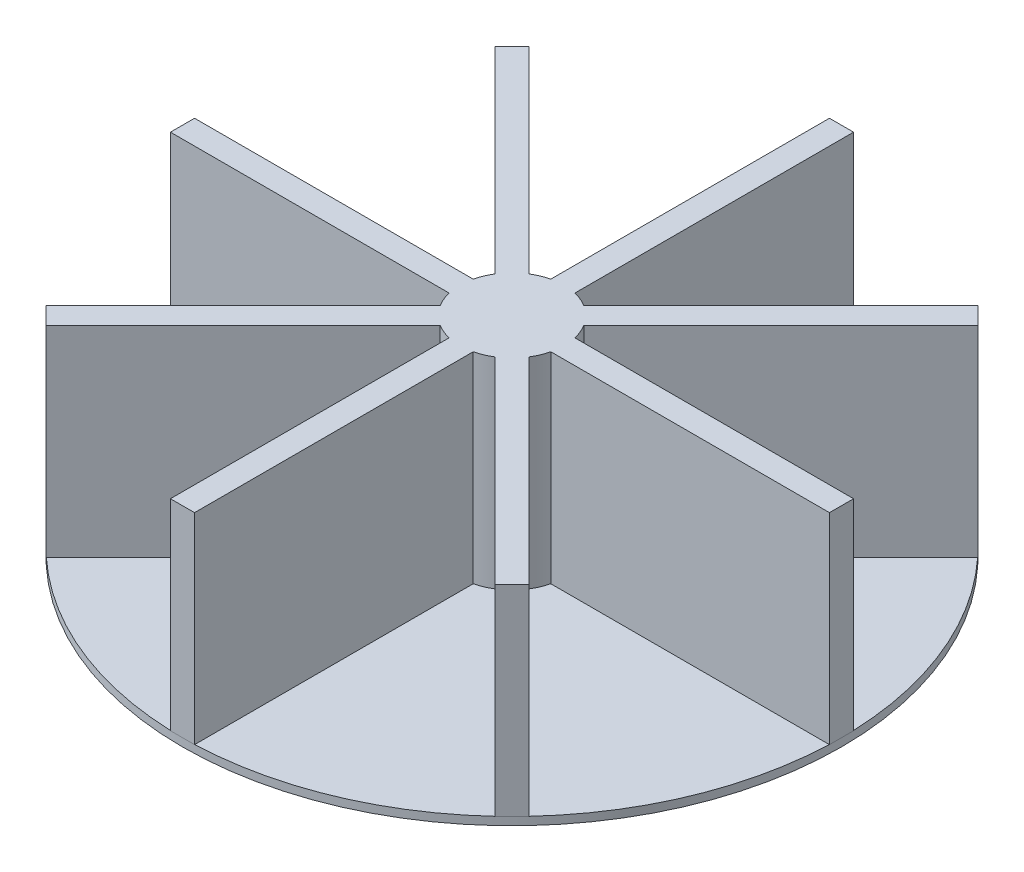
from build123d import *

# Parameters (mm, degrees)
SKETCH1_R            = 41
BOSS_EXTRUDE1_DEPTH  = 1
SKETCH6_W            = 3
SKETCH6_H            = 41
BOSS_EXTRUDE7_DEPTH  = 25
SKETCH7_R            = 6
BOSS_EXTRUDE8_DEPTH  = 24
SKETCH9_R            = 6
CUT_EXTRUDE3_DEPTH   = 5
CIRPATTERN1_COUNT    = 8
SKETCH11_R           = 6
CUT_EXTRUDE5_DEPTH   = 6
BOSS_EXTRUDE9_DEPTH  = 2
CIRPATTERN2_COUNT    = 8
FILLET1_R            = 1
SKETCH13_R           = 6.5
BOSS_EXTRUDE17_DEPTH = 6
SKETCH16_R           = 6.5
SKETCH16_R_2         = 6
BOSS_EXTRUDE18_DEPTH = 25
SKETCH15_R           = 6
BOSS_EXTRUDE19_DEPTH = 3
SKETCH17_R           = 3.075
CUT_EXTRUDE10_DEPTH  = 5


with BuildPart() as part:
    # Sketch1 → Boss-Extrude1 (new body)
    with BuildSketch(Plane(origin=(0, 0, 0), x_dir=(1, 0, 0), z_dir=(0, 1, 0))):
        Circle(SKETCH1_R)
    extrude(amount=BOSS_EXTRUDE1_DEPTH)

    # Sketch6 → Boss-Extrude7 (add)
    with BuildSketch(Plane(origin=(0, 1, 0), x_dir=(1, 0, 0), z_dir=(0, 1, 0))):
        with Locations((0, -20.5)):
            Rectangle(SKETCH6_W, SKETCH6_H)
    boss_extrude7 = extrude(amount=BOSS_EXTRUDE7_DEPTH)

    # Sketch7 → Boss-Extrude8 (add)
    with BuildSketch(Plane.XZ):
        Circle(SKETCH7_R)
    extrude(amount=-BOSS_EXTRUDE8_DEPTH)

    # Sketch9 → Cut-Extrude3 (cut)
    with BuildSketch(Plane(origin=(0, 26, 0), x_dir=(1, 0, 0), z_dir=(0, 1, 0))):
        Circle(SKETCH9_R)
    extrude(amount=-CUT_EXTRUDE3_DEPTH, mode=Mode.SUBTRACT)

    # CirPattern1: Boss-Extrude7 ×8 about axis
    cirpattern1_axis = Axis((0, 0, 0), (0, 1, 0))
    for i in range(1, CIRPATTERN1_COUNT):
        add(boss_extrude7.rotate(cirpattern1_axis, i * 360 / CIRPATTERN1_COUNT))

    # Sketch11 → Cut-Extrude5 (cut)
    with BuildSketch(Plane(origin=(0, 26, 0), x_dir=(1, 0, 0), z_dir=(0, 1, 0))):
        Circle(SKETCH11_R)
    extrude(amount=-CUT_EXTRUDE5_DEPTH, mode=Mode.SUBTRACT)

    # Sketch10 → Boss-Extrude9 (add)
    with BuildSketch(Plane(origin=(0, 0, 0), x_dir=(-1, 0, 0), z_dir=(0, -1, 0))):
        Polygon((-3.142992858, 11.677824964), (-5.920826915, 10.544847493), (-7.809122701, 15.174570921), (-5.031288644, 16.307548393), align=None)
    boss_extrude9 = extrude(amount=BOSS_EXTRUDE9_DEPTH)

    # CirPattern2: Boss-Extrude9 ×8 about axis
    cirpattern2_axis = Axis((0, 0, 0), (0, 1, 0))
    for i in range(1, CIRPATTERN2_COUNT):
        add(boss_extrude9.rotate(cirpattern2_axis, i * 360 / CIRPATTERN2_COUNT))

    # Fillet1
    fillet1_edges = [part.edges().sort_by_distance(p)[0] for p in [
        (4.087140751, -2, -13.992686678),
        (6.420205673, -2, -15.741059657),
        (6.864974808, -2, -12.859709207),
        (4.531909887, -2, -11.111336228),
        (-7.004278697, -2, -12.784368578),
        (-6.590839059, -2, -15.670380994),
        (-4.238917345, -2, -13.947457824),
        (-4.652356983, -2, -11.061445408),
        (-13.992686678, -2, -4.087140751),
        (-15.741059657, -2, -6.420205673),
        (-12.859709207, -2, -6.864974808),
        (-11.111336228, -2, -4.531909887),
        (-12.784368578, -2, 7.004278697),
        (-15.670380994, -2, 6.590839059),
        (-13.947457824, -2, 4.238917345),
        (-11.061445408, -2, 4.652356983),
        (-4.087140751, -2, 13.992686678),
        (-6.420205673, -2, 15.741059657),
        (-6.864974808, -2, 12.859709207),
        (-4.531909887, -2, 11.111336228),
        (7.004278697, -2, 12.784368578),
        (6.590839059, -2, 15.670380994),
        (4.238917345, -2, 13.947457824),
        (4.652356983, -2, 11.061445408),
        (13.992686678, -2, 4.087140751),
        (15.741059657, -2, 6.420205673),
        (12.859709207, -2, 6.864974808),
        (11.111336228, -2, 4.531909887),
        (12.784368578, -2, -7.004278697),
        (15.670380994, -2, -6.590839059),
        (13.947457824, -2, -4.238917345),
        (11.061445408, -2, -4.652356983),
    ]]
    fillet(fillet1_edges, radius=FILLET1_R)

    # Sketch13 → Boss-Extrude17 (add)
    with BuildSketch(Plane(origin=(0, 20, 0), x_dir=(1, 0, 0), z_dir=(0, 1, 0))):
        Circle(SKETCH13_R)
    extrude(amount=BOSS_EXTRUDE17_DEPTH)

    # Sketch16 → Boss-Extrude18 (add)
    with BuildSketch(Plane(origin=(0, 26, 0), x_dir=(1, 0, 0), z_dir=(0, 1, 0))):
        Circle(SKETCH16_R)
        Circle(SKETCH16_R_2, mode=Mode.SUBTRACT)
    extrude(amount=-BOSS_EXTRUDE18_DEPTH)

    # Sketch15 → Boss-Extrude19 (add)
    with BuildSketch(Plane.XZ):
        Circle(SKETCH15_R)
    extrude(amount=BOSS_EXTRUDE19_DEPTH)

    # Sketch17 → Cut-Extrude10 (cut)
    with BuildSketch(Plane.XZ.offset(3)):
        Circle(SKETCH17_R)
    extrude(amount=-CUT_EXTRUDE10_DEPTH, mode=Mode.SUBTRACT)


solid = part.part
